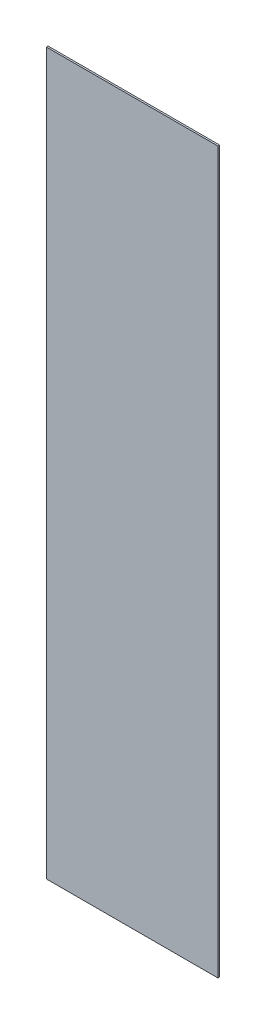
from build123d import *

# Parameters (mm, degrees)
SKIZZE1_W                       = 50
SKIZZE1_H                       = 210
AUFSATZ_LINEAR_AUSTRAGEN1_DEPTH = 0.5


with BuildPart() as part:
    # Skizze1 → Aufsatz-Linear austragen1 (new body)
    with BuildSketch(Plane.XY):
        Rectangle(SKIZZE1_W, SKIZZE1_H)
    extrude(amount=AUFSATZ_LINEAR_AUSTRAGEN1_DEPTH)


solid = part.part
